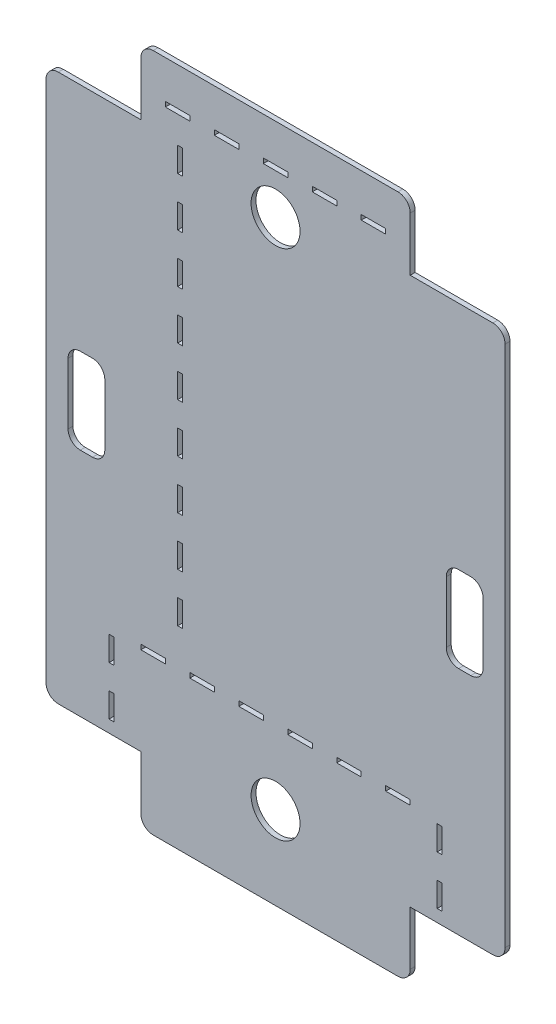
from build123d import *

# Parameters (mm, degrees)
BASE_DEPTH                   = 2
ESQUISSE2_W                  = 20
ESQUISSE2_H                  = 20
PER_AGE_PROFIL_DEPTH         = 5
ESQUISSE3_R                  = 10
TROUS_C_BLE_BREADBOARD_DEPTH = 5
SKETCH2_W                    = 10
SKETCH2_H                    = 3
SKETCH2_W_2                  = 3
SKETCH2_H_2                  = 10
CUT_EXTRUDE1_DEPTH           = 3
ENL_V_MAT_EXTRU_1_DEPTH      = 3
ESQUISSE6_W                  = 67.618725508
ESQUISSE6_H                  = 41.085883865
ESQUISSE6_W_2                = 53.230557381
ESQUISSE6_H_2                = 34.991468873
ESQUISSE6_W_3                = 73.131534877
ESQUISSE6_H_3                = 36.535913055
ESQUISSE6_W_4                = 49.288624516
ESQUISSE6_H_4                = 35.233839469
ENL_V_MAT_EXTRU_2_DEPTH      = 3
CONG_2_R                     = 5
ESQUISSE7_W                  = 1
ESQUISSE7_H                  = 170
ESQUISSE7_H_2                = 30
ESQUISSE7_W_2                = 90
ESQUISSE7_H_3                = 1
ESQUISSE7_W_3                = 110
BOSS_EXTRU_1_DEPTH           = 2
CONG_3_R                     = 5


with BuildPart() as part:
    # Esquisse1 → Base (new body)
    with BuildSketch(Plane.XY):
        Polygon((-99.748737342, 120), (-75, 144.748737342), (75, 144.748737342), (99.748737342, 120), (99.748737342, -120), (75, -144.748737342), (-75, -144.748737342), (-99.748737342, -120), align=None)
    extrude(amount=BASE_DEPTH)

    # Esquisse2 → Perçage profilé (cut)
    with BuildSketch(Plane.XY.offset(2)):
        with Locations((65, 121.748737342)):
            Rectangle(ESQUISSE2_W, ESQUISSE2_H)
        with Locations((-65, 121.748737342)):
            Rectangle(ESQUISSE2_W, ESQUISSE2_H)
        with Locations((65, -121.748737342)):
            Rectangle(ESQUISSE2_W, ESQUISSE2_H)
        with Locations((-65, -121.748737342)):
            Rectangle(ESQUISSE2_W, ESQUISSE2_H)
    extrude(amount=-PER_AGE_PROFIL_DEPTH, mode=Mode.SUBTRACT)

    # Esquisse3 → Trous câble breadboard (cut)
    with BuildSketch(Plane.XY.offset(2)):
        with Locations((0, -104.748737342)):
            Circle(ESQUISSE3_R)
        with Locations((0, 104.748737342)):
            Circle(ESQUISSE3_R)
        with BuildLine():
            Line((79.748737342, -17.5), (74.748737342, -17.5))
            ThreePointArc((74.748737342, -17.5), (71.213203436, -16.035533906), (69.748737342, -12.5))
            Line((69.748737342, -12.5), (69.748737342, 12.5))
            ThreePointArc((69.748737342, 12.5), (71.213203436, 16.035533906), (74.748737342, 17.5))
            Line((74.748737342, 17.5), (79.748737342, 17.5))
            ThreePointArc((79.748737342, 17.5), (83.284271247, 16.035533906), (84.748737342, 12.5))
            Line((84.748737342, 12.5), (84.748737342, -12.5))
            ThreePointArc((84.748737342, -12.5), (83.284271247, -16.035533906), (79.748737342, -17.5))
        make_face()
        with BuildLine():
            Line((-79.748737342, 17.5), (-74.748737342, 17.5))
            ThreePointArc((-74.748737342, 17.5), (-71.213203436, 16.035533906), (-69.748737342, 12.5))
            Line((-69.748737342, 12.5), (-69.748737342, -12.5))
            ThreePointArc((-69.748737342, -12.5), (-71.213203436, -16.035533906), (-74.748737342, -17.5))
            Line((-74.748737342, -17.5), (-79.748737342, -17.5))
            ThreePointArc((-79.748737342, -17.5), (-83.284271247, -16.035533906), (-84.748737342, -12.5))
            Line((-84.748737342, -12.5), (-84.748737342, 12.5))
            ThreePointArc((-84.748737342, 12.5), (-83.284271247, 16.035533906), (-79.748737342, 17.5))
        make_face()
    extrude(amount=-TROUS_C_BLE_BREADBOARD_DEPTH, mode=Mode.SUBTRACT)

    # Sketch2 → Cut-Extrude1 (cut, through all)
    with BuildSketch(Plane.XY.offset(2)):
        with Locations((-40, 121.748737342)):
            Rectangle(SKETCH2_W, SKETCH2_H)
        with Locations((-20, 121.748737342)):
            Rectangle(SKETCH2_W, SKETCH2_H)
        with Locations((0, 121.748737342)):
            Rectangle(SKETCH2_W, SKETCH2_H)
        with Locations((20, 121.748737342)):
            Rectangle(SKETCH2_W, SKETCH2_H)
        with Locations((40, 121.748737342)):
            Rectangle(SKETCH2_W, SKETCH2_H)
        with Locations((-66.5, -101.748737342)):
            Rectangle(SKETCH2_W_2, SKETCH2_H_2)
        with Locations((-38.5, 85.248737342)):
            Rectangle(SKETCH2_W_2, SKETCH2_H_2)
        with Locations((-38.5, 105.248737342)):
            Rectangle(SKETCH2_W_2, SKETCH2_H_2)
        with Locations((-66.5, -81.748737342)):
            Rectangle(SKETCH2_W_2, SKETCH2_H_2)
        with Locations((66.5, -81.748737342)):
            Rectangle(SKETCH2_W_2, SKETCH2_H_2)
        with Locations((66.5, -101.748737342)):
            Rectangle(SKETCH2_W_2, SKETCH2_H_2)
        with Locations((-30, -75.248737342)):
            Rectangle(SKETCH2_W, SKETCH2_H)
        with Locations((-50, -75.248737342)):
            Rectangle(SKETCH2_W, SKETCH2_H)
        with Locations((-10, -75.248737342)):
            Rectangle(SKETCH2_W, SKETCH2_H)
        with Locations((10, -75.248737342)):
            Rectangle(SKETCH2_W, SKETCH2_H)
        with Locations((30, -75.248737342)):
            Rectangle(SKETCH2_W, SKETCH2_H)
        with Locations((50, -75.248737342)):
            Rectangle(SKETCH2_W, SKETCH2_H)
        with Locations((-38.5, 65.248737342)):
            Rectangle(SKETCH2_W_2, SKETCH2_H_2)
        with Locations((-38.5, 45.248737342)):
            Rectangle(SKETCH2_W_2, SKETCH2_H_2)
        with Locations((-38.5, 25.248737342)):
            Rectangle(SKETCH2_W_2, SKETCH2_H_2)
        with Locations((-38.5, 5.248737342)):
            Rectangle(SKETCH2_W_2, SKETCH2_H_2)
        with Locations((-38.5, -14.751262658)):
            Rectangle(SKETCH2_W_2, SKETCH2_H_2)
        with Locations((-38.5, -34.751262658)):
            Rectangle(SKETCH2_W_2, SKETCH2_H_2)
        with Locations((-38.5, -54.751262658)):
            Rectangle(SKETCH2_W_2, SKETCH2_H_2)
    extrude(amount=-CUT_EXTRUDE1_DEPTH, mode=Mode.SUBTRACT)

    # Esquisse5 → Enlèv. mat.-Extru.1 (cut, through all)
    with BuildSketch(Plane.XY.offset(2)):
        Polygon((-16.674289333, 205.045094985), (192.81948305, 199.325128504), (168.509625504, -212.512458161), (-168.968396902, -176.762667652), (-185.413300536, 175.015270958), align=None)
        Polygon((-72.514718626, 138.748737342), (72.514718626, 138.748737342), (93.748737342, 117.514718626), (93.748737342, -117.514718626), (72.514718626, -138.748737342), (-72.514718626, -138.748737342), (-93.748737342, -117.514718626), (-93.748737342, 117.514718626), align=None, mode=Mode.SUBTRACT)
    extrude(amount=-ENL_V_MAT_EXTRU_1_DEPTH, mode=Mode.SUBTRACT)

    # Esquisse6 → Enlèv. mat.-Extru.2 (cut, through all)
    with BuildSketch(Plane.XY.offset(2)):
        with Locations((-88.809362754, 132.291679275)):
            Rectangle(ESQUISSE6_W, ESQUISSE6_H)
        with Locations((81.615278691, 129.244471779)):
            Rectangle(ESQUISSE6_W_2, ESQUISSE6_H_2)
        with Locations((91.565767439, -130.01669387)):
            Rectangle(ESQUISSE6_W_3, ESQUISSE6_H_3)
        with Locations((-79.644312258, -129.365657077)):
            Rectangle(ESQUISSE6_W_4, ESQUISSE6_H_4)
    extrude(amount=-ENL_V_MAT_EXTRU_2_DEPTH, mode=Mode.SUBTRACT)

    # Congé2
    cong_2_edges = [part.edges().sort_by_distance(p)[0] for p in [
        (55, -138.748737342, 1),
        (-55, -138.748737342, 1),
        (-55, 138.748737342, 1),
        (55, 138.748737342, 1),
    ]]
    fillet(cong_2_edges, radius=CONG_2_R)

    # Esquisse7 → Boss.-Extru.1 (add)
    with BuildSketch(Plane.XY.offset(2)):
        with Locations((-37.5, 25.248737342)):
            Rectangle(ESQUISSE7_W, ESQUISSE7_H)
        with Locations((-65.5, -91.748737342)):
            Rectangle(ESQUISSE7_W, ESQUISSE7_H_2)
        with Locations((65.5, -91.748737342)):
            Rectangle(ESQUISSE7_W, ESQUISSE7_H_2)
        with Locations((0, 120.748737342)):
            Rectangle(ESQUISSE7_W_2, ESQUISSE7_H_3)
        with Locations((0, -76.248737342)):
            Rectangle(ESQUISSE7_W_3, ESQUISSE7_H_3)
    extrude(amount=-BOSS_EXTRU_1_DEPTH)

    # Congé3
    cong_3_edges = [part.edges().sort_by_distance(p)[0] for p in [
        (-93.748737342, 111.748737342, 1),
        (-93.748737342, -111.748737342, 1),
        (93.748737342, 111.748737342, 1),
        (93.748737342, -111.748737342, 1),
    ]]
    fillet(cong_3_edges, radius=CONG_3_R)


solid = part.part
